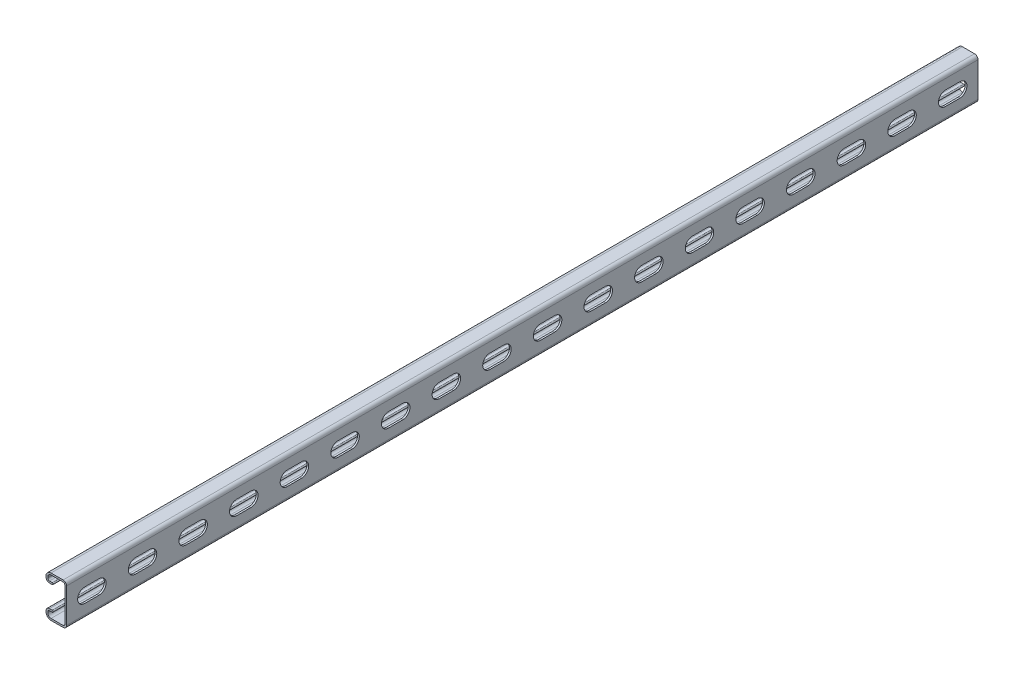
from build123d import *

# Parameters (mm, degrees)
BOSS_EXTRUDE1_DEPTH = 914.4
CUT_EXTRUDE1_DEPTH  = 1.778
LPATTERN1_COUNT     = 18
LPATTERN1_PITCH     = 50.8


with BuildPart() as part:
    # Sketch1 → Boss-Extrude1 (new body)
    with BuildSketch(Plane.XY):
        with BuildLine():
            Line((-15.58925, 20.6375), (-3.46075, 20.6375))
            ThreePointArc((-3.46075, 20.6375), (-1.013630207, 19.623869793), (0, 17.17675))
            Line((0, 17.17675), (0, -17.17675))
            ThreePointArc((0, -17.17675), (-1.013630207, -19.623869793), (-3.46075, -20.6375))
            Line((-3.46075, -20.6375), (-15.58925, -20.6375))
            ThreePointArc((-15.58925, -20.6375), (-19.158901808, -19.158901808), (-20.6375, -15.58925))
            Line((-20.6375, -15.58925), (-20.6375, -14.57325))
            ThreePointArc((-20.6375, -14.57325), (-19.623869793, -12.126130207), (-17.17675, -11.1125))
            Line((-17.17675, -11.1125), (-14.3891, -11.1125))
            ThreePointArc((-14.3891, -11.1125), (-13.5001, -12.0015), (-14.3891, -12.8905))
            Line((-14.3891, -12.8905), (-17.17675, -12.8905))
            ThreePointArc((-17.17675, -12.8905), (-18.366633936, -13.383366064), (-18.8595, -14.57325))
            Line((-18.8595, -14.57325), (-18.8595, -15.58925))
            ThreePointArc((-18.8595, -15.58925), (-17.901665951, -17.901665951), (-15.58925, -18.8595))
            Line((-15.58925, -18.8595), (-3.46075, -18.8595))
            ThreePointArc((-3.46075, -18.8595), (-2.270866064, -18.366633936), (-1.778, -17.17675))
            Line((-1.778, -17.17675), (-1.778, 17.17675))
            ThreePointArc((-1.778, 17.17675), (-2.270866064, 18.366633936), (-3.46075, 18.8595))
            Line((-3.46075, 18.8595), (-15.58925, 18.8595))
            ThreePointArc((-15.58925, 18.8595), (-17.901665951, 17.901665951), (-18.8595, 15.58925))
            Line((-18.8595, 15.58925), (-18.8595, 14.57325))
            ThreePointArc((-18.8595, 14.57325), (-18.366633936, 13.383366064), (-17.17675, 12.8905))
            Line((-17.17675, 12.8905), (-14.3891, 12.8905))
            ThreePointArc((-14.3891, 12.8905), (-13.5001, 12.0015), (-14.3891, 11.1125))
            Line((-14.3891, 11.1125), (-17.17675, 11.1125))
            ThreePointArc((-17.17675, 11.1125), (-19.623869793, 12.126130207), (-20.6375, 14.57325))
            Line((-20.6375, 14.57325), (-20.6375, 15.58925))
            ThreePointArc((-20.6375, 15.58925), (-19.158901808, 19.158901808), (-15.58925, 20.6375))
        make_face()
    extrude(amount=-BOSS_EXTRUDE1_DEPTH)

    # Sketch2 → Cut-Extrude1 (cut)
    with BuildSketch(Plane(origin=(0, 0, 0), x_dir=(0, 0, -1), z_dir=(1, 0, 0))):
        with BuildLine():
            Line((18.25625, 7.14375), (32.54375, 7.14375))
            ThreePointArc((32.54375, 7.14375), (39.6875, 0), (32.54375, -7.14375))
            Line((32.54375, -7.14375), (18.25625, -7.14375))
            ThreePointArc((18.25625, -7.14375), (11.1125, 0), (18.25625, 7.14375))
        make_face()
    cut_extrude1 = extrude(amount=-CUT_EXTRUDE1_DEPTH, mode=Mode.SUBTRACT)

    # LPattern1: Cut-Extrude1 ×18
    with Locations(*[(0, 0, -i * LPATTERN1_PITCH) for i in range(1, LPATTERN1_COUNT)]):
        add(cut_extrude1, mode=Mode.SUBTRACT)


solid = part.part
